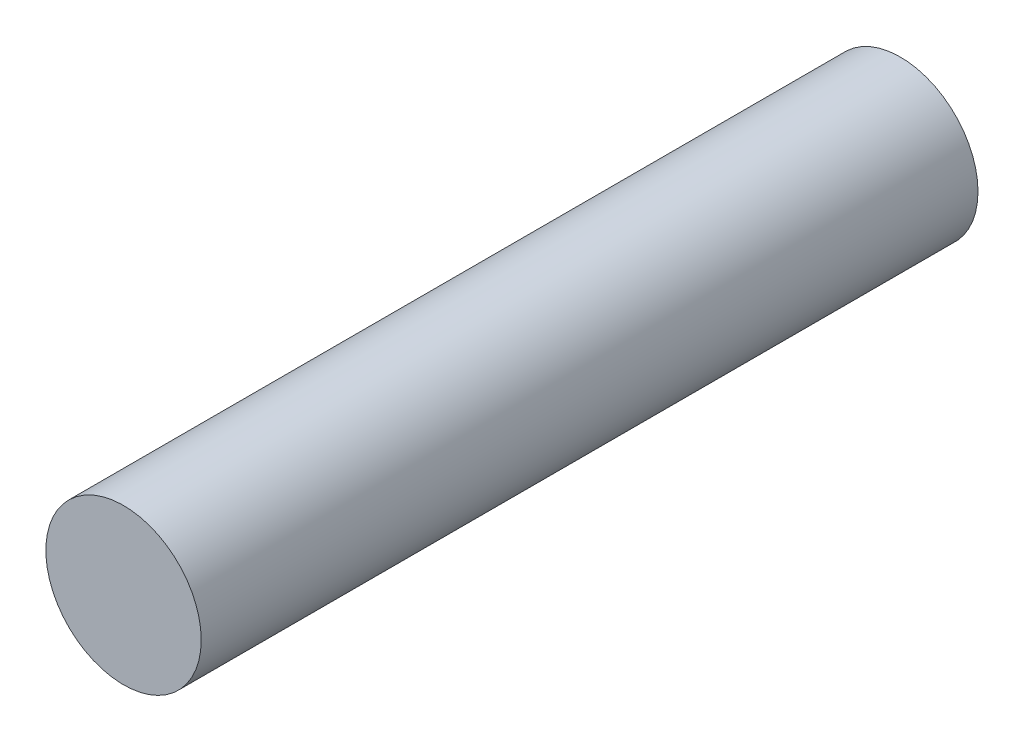
from build123d import *

# Parameters (mm, degrees)
SKETCH1_R           = 2
BOSS_EXTRUDE1_DEPTH = 20


with BuildPart() as part:
    # Sketch1 → Boss-Extrude1 (new body)
    with BuildSketch(Plane.XY):
        Circle(SKETCH1_R)
    extrude(amount=BOSS_EXTRUDE1_DEPTH)


solid = part.part
